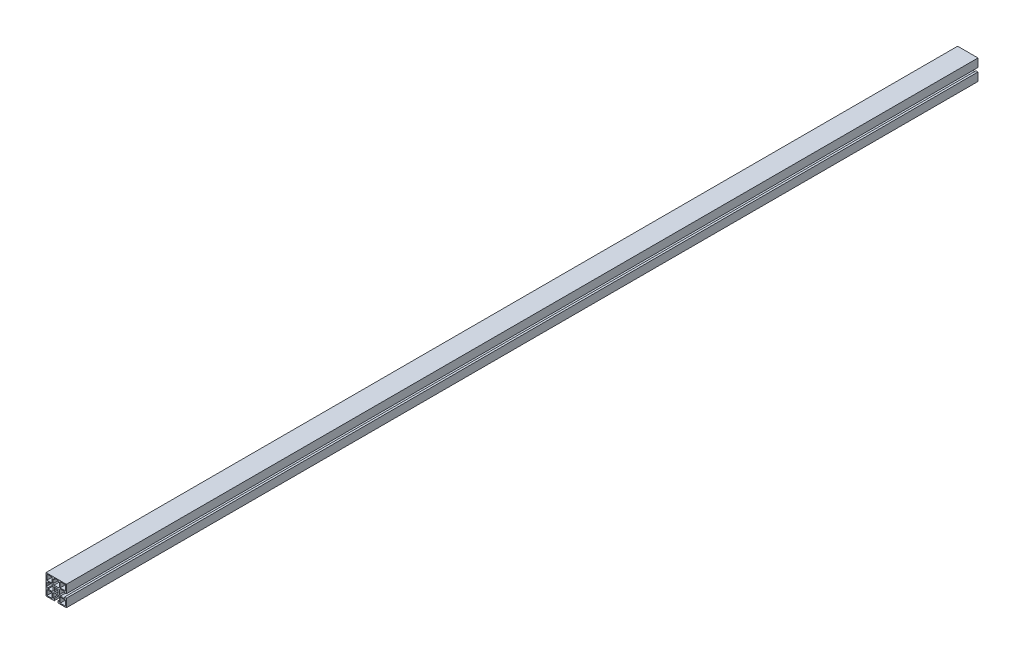
from build123d import *

# Parameters (mm, degrees)
SKETCH1_W           = 11.699975178
SKETCH1_H           = 11.699996949
SKETCH1_W_2         = 11.699990436
SKETCH1_H_2         = 11.699981689
SKETCH1_W_3         = 11.699990437
SKETCH1_H_3         = 11.699975177
SKETCH1_W_4         = 11.699981689
SKETCH1_H_4         = 11.699990436
BOSS_EXTRUDE1_DEPTH = 2012.95


with BuildPart() as part:
    # Sketch1 → Boss-Extrude1 (new body)
    with BuildSketch(Plane.XY):
        Polygon((22.500515052, 22.499297556), (-22.499484399, 22.499298105), (-22.499484948, -22.500701346), (-4.249491942, -22.500701568), (-4.249491942, -22.200733242), (-4.24949208, -18.000719999), (-6.799479919, -18.000719999), (-6.799480207, -9.200732353), (-4.799480391, -7.200732362), (4.800525817, -7.200732047), (6.8005258, -9.200731855), (6.800526088, -18.000720263), (4.250507877, -18.000720263), (4.250508015, -22.200733153), (4.250508015, -22.500701672), (22.500514502, -22.500701895), (22.500514725, -4.250714302), (22.200520351, -4.250714302), (18.000507108, -4.25071444), (18.000507108, -6.800702279), (9.200519462, -6.800702567), (7.200519471, -4.800702751), (7.200519156, 4.799303458), (9.200518964, 6.79930344), (18.000507424, 6.799303729), (18.000507424, 4.249285514), (22.200520261, 4.249285652), (22.500514829, 4.249285652), align=None)
        with BuildLine():
            Line((-4.249491247, 17.999291576), (-4.249490956, 22.199304807))
            Line((-4.249490956, 22.199304807), (-3.949472548, 22.199304807))
            Line((-3.949472548, 22.199304807), (-3.481695222, 21.73152644))
            ThreePointArc((-3.481695222, 21.73152644), (-2.670636178, 21.189593132), (-1.713926324, 20.999291428))
            Line((-1.713926324, 20.999291428), (1.714975167, 20.999291428))
            ThreePointArc((1.714975167, 20.999291428), (2.671722509, 21.189608628), (3.482801459, 21.731583767))
            Line((3.482801459, 21.731583767), (3.950490798, 22.199304487))
            Line((3.950490798, 22.199304487), (4.250509108, 22.199304487))
            Line((4.250509108, 22.199304487), (4.250508817, 17.999291575))
            Line((4.250508817, 17.999291575), (6.800527063, 17.999291575))
            Line((6.800527063, 17.999291575), (6.800526453, 9.199302988))
            Line((6.800526453, 9.199302988), (4.800526064, 7.199302969))
            Line((4.800526064, 7.199302969), (-4.799479817, 7.199303635))
            Line((-4.799479817, 7.199303635), (-6.799479854, 9.199304042))
            Line((-6.799479854, 9.199304042), (-6.799479244, 17.999291576))
            Line((-6.799479244, 17.999291576), (-4.249491247, 17.999291576))
        make_face(mode=Mode.SUBTRACT)
        with BuildLine():
            Line((-17.99949762, -4.250714253), (-22.199510799, -4.250714391))
            Line((-22.199510799, -4.250714391), (-22.199510799, -3.950696126))
            Line((-22.199510799, -3.950696126), (-21.731790056, -3.48300681))
            ThreePointArc((-21.731790056, -3.48300681), (-21.189814855, -2.671927844), (-20.999497617, -1.71518046))
            Line((-20.999497617, -1.71518046), (-20.999497617, 1.713721031))
            ThreePointArc((-20.999497617, 1.713721031), (-21.189799286, 2.670430863), (-21.731732544, 3.481489907))
            Line((-21.731732544, 3.481489907), (-22.199510888, 3.949267256))
            Line((-22.199510888, 3.949267256), (-22.199510888, 4.249285566))
            Line((-22.199510888, 4.249285566), (-17.999497356, 4.249285704))
            Line((-17.999497356, 4.249285704), (-17.999497356, 6.79927354))
            Line((-17.999497356, 6.79927354), (-9.199509947, 6.799273828))
            Line((-9.199509947, 6.799273828), (-7.199509956, 4.799274012))
            Line((-7.199509956, 4.799274012), (-7.199509641, -4.800732197))
            Line((-7.199509641, -4.800732197), (-9.199509449, -6.800732179))
            Line((-9.199509449, -6.800732179), (-17.99949762, -6.800732468))
            Line((-17.99949762, -6.800732468), (-17.99949762, -4.250714253))
        make_face(mode=Mode.SUBTRACT)
        with Locations((-14.649542346, -14.650709384)):
            Rectangle(SKETCH1_W, SKETCH1_H, mode=Mode.SUBTRACT)
        with Locations((14.65050626, -14.650767962)):
            Rectangle(SKETCH1_W_2, SKETCH1_H_2, mode=Mode.SUBTRACT)
        with BuildLine():
            Line((-3.181457266, -4.596908447), (-4.595670829, -3.182694885))
            Line((-4.595670829, -3.182694885), (-3.26221457, -1.849238626))
            ThreePointArc((-3.26221457, -1.849238626), (-3.749476751, -0.00071437), (-3.26221457, 1.847809887))
            Line((-3.26221457, 1.847809887), (-4.595670829, 3.181266146))
            Line((-4.595670829, 3.181266146), (-3.181457266, 4.595479708))
            Line((-3.181457266, 4.595479708), (-1.848001007, 3.262023449))
            ThreePointArc((-1.848001007, 3.262023449), (0.000523249, 3.74928563), (1.849047505, 3.262023449))
            Line((1.849047505, 3.262023449), (3.182503764, 4.595479708))
            Line((3.182503764, 4.595479708), (4.596717327, 3.181266146))
            Line((4.596717327, 3.181266146), (3.263261068, 1.847809887))
            ThreePointArc((3.263261068, 1.847809887), (3.750523249, -0.00071437), (3.263261068, -1.849238626))
            Line((3.263261068, -1.849238626), (4.596717327, -3.182694885))
            Line((4.596717327, -3.182694885), (3.182503764, -4.596908447))
            Line((3.182503764, -4.596908447), (1.849047505, -3.263452188))
            ThreePointArc((1.849047505, -3.263452188), (0.000523249, -3.75071437), (-1.848001007, -3.263452188))
            Line((-1.848001007, -3.263452188), (-3.181457266, -4.596908447))
        make_face(mode=Mode.SUBTRACT)
        with Locations((-14.64949028, 14.649335967)):
            Rectangle(SKETCH1_W_3, SKETCH1_H_3, mode=Mode.SUBTRACT)
        with Locations((14.650561583, 14.6492839)):
            Rectangle(SKETCH1_W_4, SKETCH1_H_4, mode=Mode.SUBTRACT)
    extrude(amount=BOSS_EXTRUDE1_DEPTH)


solid = part.part
